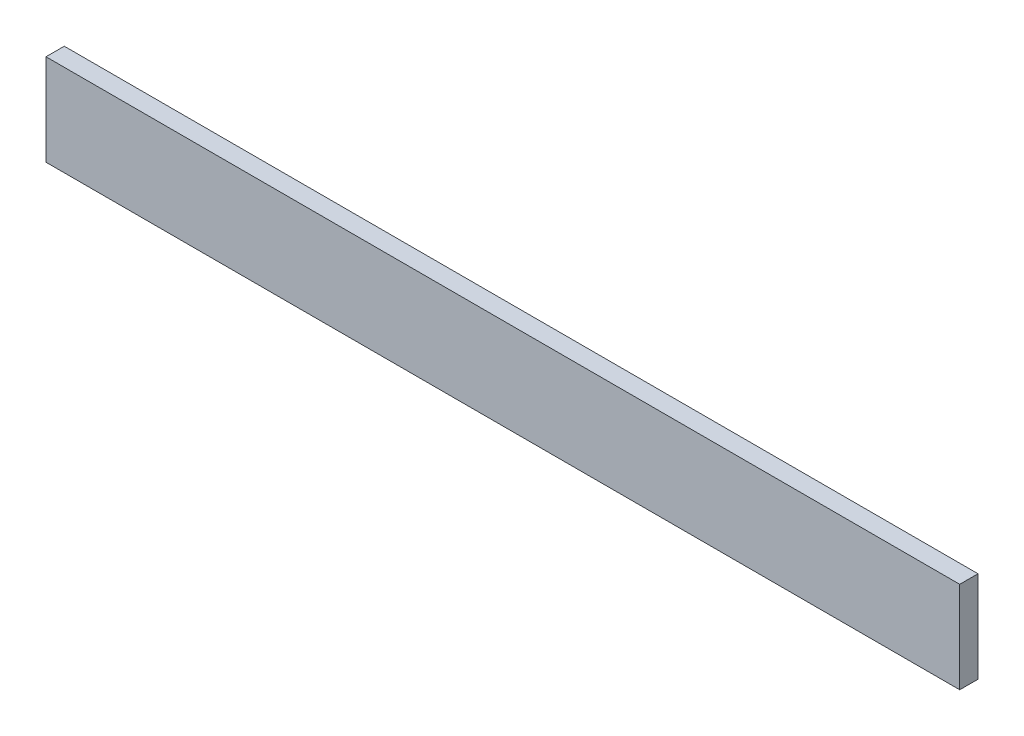
from build123d import *

# Parameters (mm, degrees)
SKETCH1_W           = 635
SKETCH1_H           = 63.5
BOSS_EXTRUDE1_DEPTH = 12.7


with BuildPart() as part:
    # Sketch1 → Boss-Extrude1 (new body)
    with BuildSketch(Plane.XY):
        Rectangle(SKETCH1_W, SKETCH1_H)
    extrude(amount=BOSS_EXTRUDE1_DEPTH)


solid = part.part
